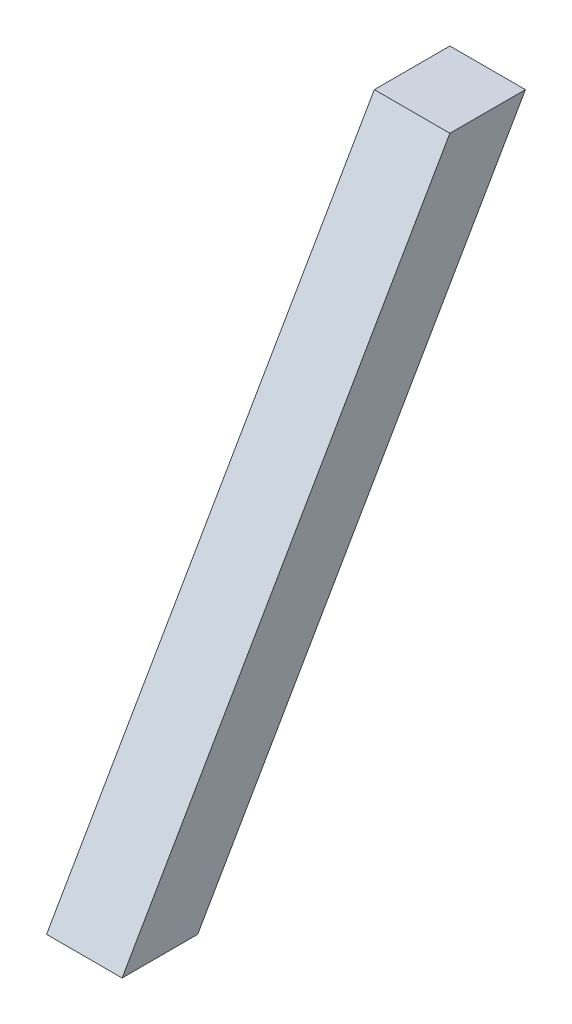
from build123d import *

# Parameters (mm, degrees)
BOSS_EXTRUDE2_DEPTH = 40


with BuildPart() as part:
    # Sketch2 → Boss-Extrude2 (new body)
    with BuildSketch(Plane(origin=(0, 0, 0), x_dir=(0, 0, -1), z_dir=(1, 0, 0))):
        Polygon((-20, 0), (20, 0), (193.5, 300.510815113), (153.5, 300.510815113), align=None)
    extrude(amount=BOSS_EXTRUDE2_DEPTH)


solid = part.part
